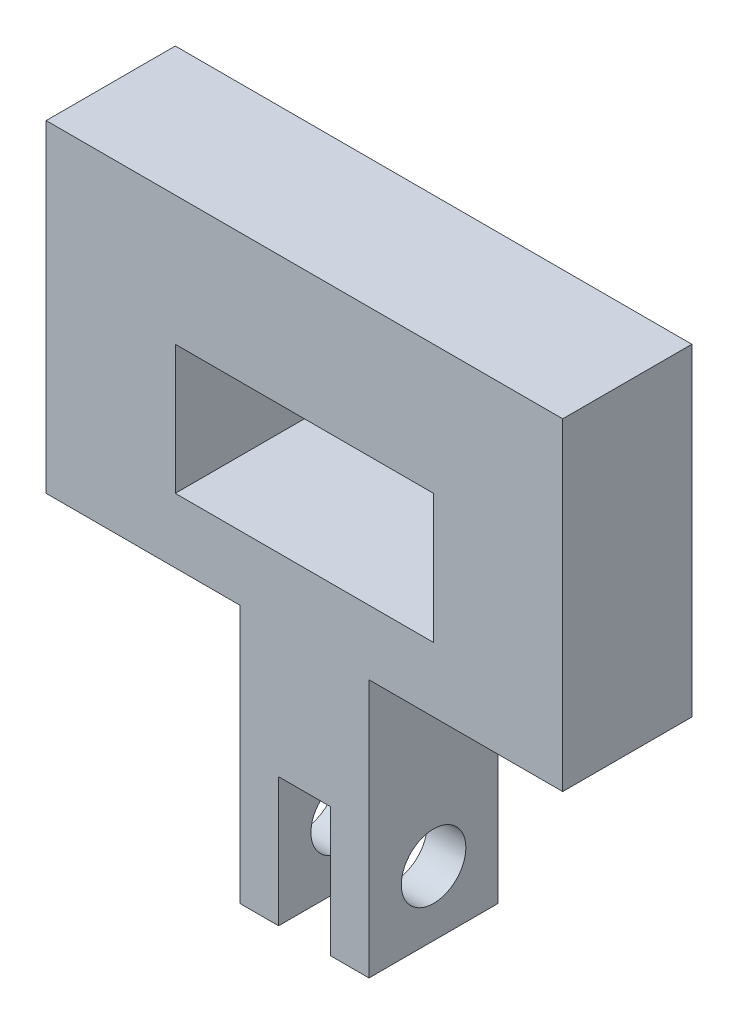
from build123d import *

# Parameters (mm, degrees)
BOSS_EXTRU_1_DEPTH      = 5
BOSS_EXTRU_1_DEPTH_BACK = 5
ESQUISSE1_W             = 20
ESQUISSE1_H             = 10
ESQUISSE3_R             = 2.5
ENL_V_MAT_EXTRU_1_DEPTH = 40.37003937


with BuildPart() as part:
    # Esquisse1 → Boss.-Extru.1 (new, two sides: drawn at the far end of the back side and taken through both)
    with BuildSketch(Plane.XY.offset(-BOSS_EXTRU_1_DEPTH_BACK)):
        Polygon((-20, 15), (20, 15), (20, -10), (5, -10), (5, -30), (2, -30), (2, -20), (-2, -20), (-2, -30), (-5, -30), (-5, -10), (-20, -10), align=None)
        Rectangle(ESQUISSE1_W, ESQUISSE1_H, mode=Mode.SUBTRACT)
    extrude(amount=BOSS_EXTRU_1_DEPTH + BOSS_EXTRU_1_DEPTH_BACK)

    # Esquisse3 → Enlèv. mat.-Extru.1 (cut, through all)
    with BuildSketch(Plane(origin=(5, 0, 0), x_dir=(0, 0, -1), z_dir=(1, 0, 0))):
        with Locations((0, -25)):
            Circle(ESQUISSE3_R)
    extrude(amount=-ENL_V_MAT_EXTRU_1_DEPTH, mode=Mode.SUBTRACT)


solid = part.part
